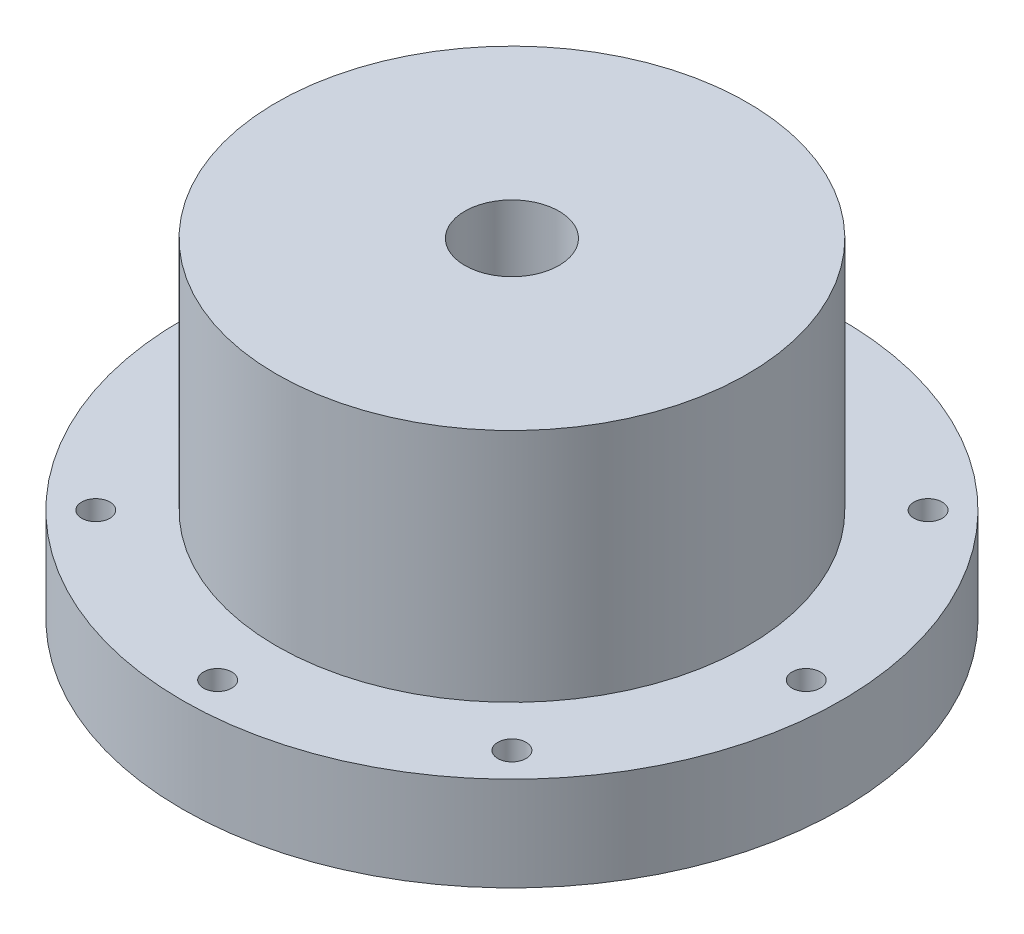
from build123d import *

# Parameters (mm, degrees)
SKETCH1_R           = 70
SKETCH1_R_2         = 10
BOSS_EXTRUDE1_DEPTH = 20
SKETCH1_3_R         = 50
SKETCH1_3_R_2       = 10
BOSS_EXTRUDE2_DEPTH = 70
SKETCH2_R           = 3
CUT_EXTRUDE1_DEPTH  = 122.24355653


with BuildPart() as part:
    # Sketch1 → Boss-Extrude1 (new body)
    with BuildSketch(Plane(origin=(0, 0, 0), x_dir=(1, 0, 0), z_dir=(0, 1, 0))):
        Circle(SKETCH1_R)
        Circle(SKETCH1_R_2, mode=Mode.SUBTRACT)
    extrude(amount=BOSS_EXTRUDE1_DEPTH)

    # Sketch1_3 → Boss-Extrude2 (add)
    with BuildSketch(Plane(origin=(0, 0, 0), x_dir=(1, 0, 0), z_dir=(0, 1, 0))):
        Circle(SKETCH1_3_R)
        Circle(SKETCH1_3_R_2, mode=Mode.SUBTRACT)
    extrude(amount=BOSS_EXTRUDE2_DEPTH)

    # Sketch2 → Cut-Extrude1 (cut, through all)
    with BuildSketch(Plane.XZ):
        with Locations((0, 62.5)):
            Circle(SKETCH2_R)
        with Locations((-44.194173824, 44.194173824)):
            Circle(SKETCH2_R)
        with Locations((44.194173824, 44.194173824)):
            Circle(SKETCH2_R)
        with Locations((-62.5, 0)):
            Circle(SKETCH2_R)
        with Locations((62.5, 0)):
            Circle(SKETCH2_R)
        with Locations((-44.194173824, -44.194173824)):
            Circle(SKETCH2_R)
        with Locations((44.194173824, -44.194173824)):
            Circle(SKETCH2_R)
        with Locations((0, -62.5)):
            Circle(SKETCH2_R)
    extrude(amount=-CUT_EXTRUDE1_DEPTH, mode=Mode.SUBTRACT)


solid = part.part
